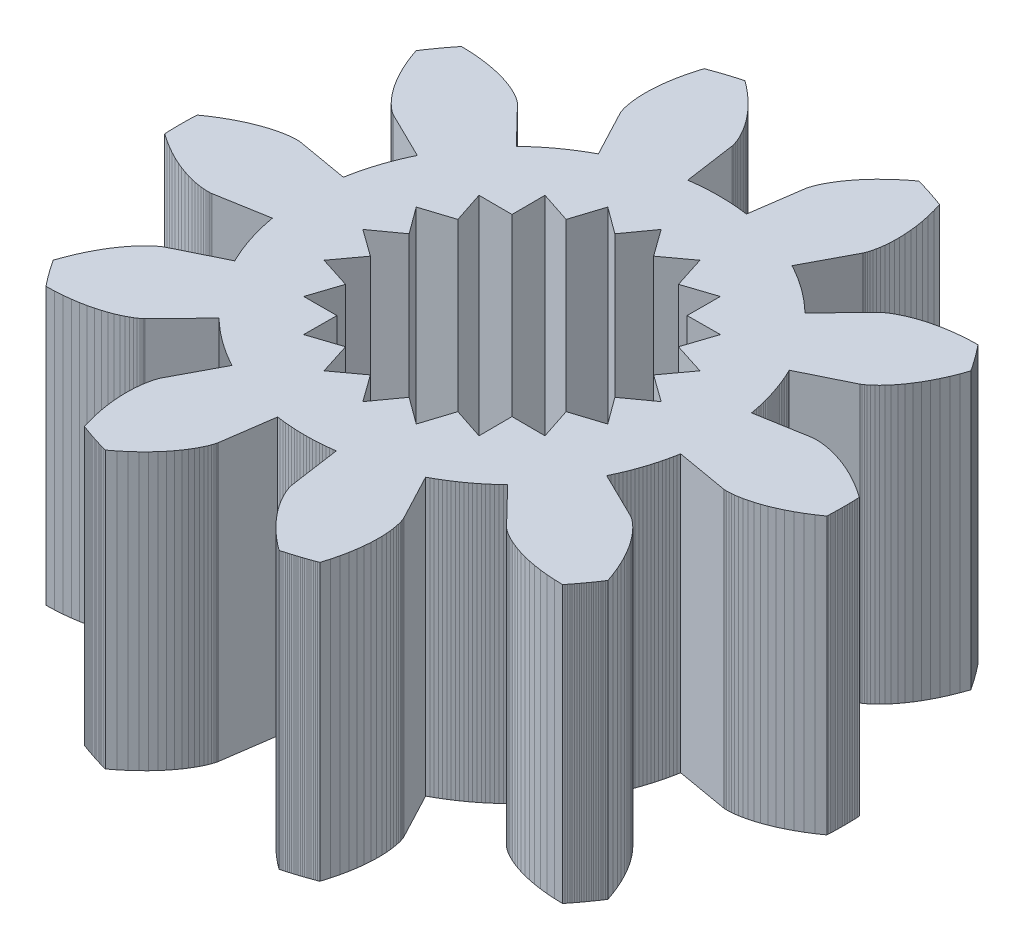
from build123d import *

# Parameters (mm, degrees)
BOSS_EXTRUDE1_DEPTH = 5
SKETCH2_R           = 1.5
CUT_EXTRUDE1_DEPTH  = 6
CUT_EXTRUDE2_DEPTH  = 6


with BuildPart() as part:
    # Sketch1 → Boss-Extrude1 (new body)
    with BuildSketch(Plane(origin=(0, 0, 0), x_dir=(1, 0, 0), z_dir=(0, 1, 0))):
        Polygon((3.6946769, -0.6417654), (4.6291475, -0.8040829), (4.6332094, -0.8046724), (4.6454524, -0.8059869), (4.6659298, -0.8073423), (4.6946521, -0.8080515), (4.7315867, -0.8074275), (4.7766581, -0.8047855), (4.8297479, -0.7994452), (4.8906949, -0.7907331), (4.9592959, -0.7779854), (5.035306, -0.7605497), (5.1184393, -0.7377878), (5.2083696, -0.7090775), (5.3047313, -0.6738155), (5.4071205, -0.631419), (5.515096, -0.5813282), (5.6281806, -0.523008), (5.7458624, -0.4559506), (5.8675963, -0.379677), (5.9928055, -0.2937389), (5.9942402, -0.26284), (5.9955155, -0.2319341), (5.9966316, -0.201022), (5.9975882, -0.1701046), (5.9983855, -0.1391826), (5.9990233, -0.108257), (5.9995017, -0.0773285), (5.9998206, -0.0463979), (5.9999801, -0.0154661), (5.9999801, 0.0154661), (5.9998206, 0.0463979), (5.9995017, 0.0773285), (5.9990233, 0.108257), (5.9983855, 0.1391826), (5.9975882, 0.1701046), (5.9966316, 0.201022), (5.9955155, 0.2319341), (5.9942402, 0.26284), (5.9928055, 0.2937389), (5.8675963, 0.379677), (5.7458624, 0.4559506), (5.6281806, 0.523008), (5.515096, 0.5813282), (5.4071205, 0.631419), (5.3047313, 0.6738155), (5.2083696, 0.7090775), (5.1184393, 0.7377878), (5.035306, 0.7605497), (4.9592959, 0.7779854), (4.8906949, 0.7907331), (4.8297479, 0.7994452), (4.7766581, 0.8047855), (4.7315867, 0.8074275), (4.6946521, 0.8080515), (4.6659298, 0.8073423), (4.6454524, 0.8059869), (4.6332094, 0.8046724), (4.6291475, 0.8040829), (3.6946769, 0.6417654), (3.6846589, 0.6969853), (3.6738157, 0.7520491), (3.6621497, 0.8069445), (3.6496635, 0.8616591), (3.6363598, 0.9161808), (3.6222417, 0.9704972), (3.6073123, 1.0245963), (3.591575, 1.078466), (3.5750333, 1.132094), (3.5576909, 1.1854685), (3.5395516, 1.2385775), (3.5206196, 1.2914091), (3.5008991, 1.3439515), (3.4803944, 1.3961929), (3.4591103, 1.4481215), (3.4370514, 1.4997258), (3.4142227, 1.5509942), (3.3906294, 1.6019152), (3.3662766, 1.6524775), (4.217687, 2.0704279), (4.2213197, 2.0723385), (4.2319972, 2.0784713), (4.2493604, 2.0894111), (4.2730141, 2.1057199), (4.3025281, 2.1279343), (4.3374387, 2.156564), (4.3772502, 2.1920898), (4.4214365, 2.2349618), (4.469443, 2.2855975), (4.520688, 2.3443809), (4.5745651, 2.4116603), (4.6304448, 2.4877471), (4.6876766, 2.5729146), (4.7455911, 2.6673969), (4.8035025, 2.7713877), (4.8607101, 2.8850392), (4.9165014, 3.0084614), (4.9701537, 3.1417214), (5.0209369, 3.2848429), (5.0039356, 3.3106839), (4.9868014, 3.336437), (4.9695346, 3.3621014), (4.9521358, 3.3876764), (4.9346053, 3.4131614), (4.9169437, 3.4385557), (4.8991514, 3.4638585), (4.8812288, 3.4890694), (4.8631766, 3.5141875), (4.8449951, 3.5392121), (4.8266848, 3.5641428), (4.8082463, 3.5889787), (4.7896799, 3.6137192), (4.7709863, 3.6383636), (4.7521658, 3.6629114), (4.7332191, 3.6873618), (4.7141465, 3.7117142), (4.6949487, 3.735968), (4.6756261, 3.7601225), (4.5238166, 3.7560517), (4.3804993, 3.746205), (4.2458773, 3.7312839), (4.1201102, 3.7119964), (4.0033136, 3.6890544), (3.8955589, 3.663171), (3.7968742, 3.6350586), (3.7072436, 3.605426), (3.6266082, 3.5749763), (3.5548663, 3.5444044), (3.491874, 3.5143949), (3.437446, 3.4856193), (3.3913565, 3.4587344), (3.3533401, 3.4343795), (3.3230926, 3.4131746), (3.3002726, 3.3957183), (3.2845027, 3.3825855), (3.2753706, 3.3743258), (3.2724309, 3.3714613), (2.6118362, 2.6908757), (2.571274, 2.7296611), (2.530136, 2.7678352), (2.4884313, 2.8053894), (2.4461693, 2.8423152), (2.4033593, 2.8786045), (2.3600111, 2.914249), (2.3161344, 2.9492408), (2.2717388, 2.9835721), (2.2268345, 3.0172352), (2.1814314, 3.0502224), (2.1355398, 3.0825265), (2.0891698, 3.1141402), (2.042332, 3.1450565), (1.9950367, 3.1752683), (1.9472946, 3.2047689), (1.8991163, 3.2335518), (1.8505127, 3.2616105), (1.8014946, 3.2889386), (1.7520731, 3.3155301), (2.1952135, 4.1541056), (2.1970294, 4.1577866), (2.2020629, 4.1690241), (2.2096797, 4.1880805), (2.2192299, 4.2151778), (2.2300499, 4.2504976), (2.2414651, 4.2941794), (2.2527917, 4.346321), (2.2633397, 4.4069772), (2.2724148, 4.4761599), (2.2793209, 4.5538378), (2.2833626, 4.6399361), (2.2838475, 4.7343368), (2.2800888, 4.8368788), (2.2714073, 4.9473579), (2.2571343, 5.0655277), (2.2366136, 5.1910994), (2.2092039, 5.3237434), (2.1742812, 5.463089), (2.1312411, 5.6087264), (2.1022978, 5.6196391), (2.0732986, 5.6304025), (2.0442444, 5.6410163), (2.0151358, 5.6514801), (1.9859736, 5.6617938), (1.9567587, 5.6719569), (1.9274917, 5.6819693), (1.8981736, 5.6918307), (1.868805, 5.7015408), (1.8393867, 5.7110994), (1.8099195, 5.7205062), (1.7804042, 5.729761), (1.7508416, 5.7388634), (1.7212325, 5.7478134), (1.6915776, 5.7566106), (1.6618778, 5.7652547), (1.6321338, 5.7737457), (1.6023464, 5.7820832), (1.5725164, 5.790267), (1.4520927, 5.6977423), (1.3419343, 5.6055363), (1.2417933, 5.5143362), (1.1513824, 5.4248082), (1.0703769, 5.3375964), (0.9984155, 5.2533197), (0.9351019, 5.1725708), (0.8800069, 5.095914), (0.8326693, 5.0238834), (0.7925986, 4.9569814), (0.7592759, 4.8956772), (0.7321566, 4.8404053), (0.710672, 4.7915643), (0.6942315, 4.7495152), (0.6822246, 4.7145811), (0.6740235, 4.6870454), (0.6689846, 4.6671514), (0.6664515, 4.6551015), (0.6657569, 4.6510561), (0.5313628, 3.7121629), (0.4757498, 3.7196992), (0.4200303, 3.7264024), (0.3642167, 3.7322709), (0.3083215, 3.7373036), (0.2523573, 3.7414991), (0.1963365, 3.7448567), (0.1402718, 3.7473756), (0.0841756, 3.7490551), (0.0280606, 3.749895), (-0.0280606, 3.749895), (-0.0841756, 3.7490551), (-0.1402718, 3.7473756), (-0.1963365, 3.7448567), (-0.2523573, 3.7414991), (-0.3083215, 3.7373036), (-0.3642167, 3.7322709), (-0.4200303, 3.7264024), (-0.4757498, 3.7196992), (-0.5313628, 3.7121629), (-0.6657569, 4.6510561), (-0.6664515, 4.6551015), (-0.6689846, 4.6671514), (-0.6740235, 4.6870454), (-0.6822246, 4.7145811), (-0.6942315, 4.7495152), (-0.710672, 4.7915643), (-0.7321566, 4.8404053), (-0.7592759, 4.8956772), (-0.7925986, 4.9569814), (-0.8326693, 5.0238834), (-0.8800069, 5.095914), (-0.9351019, 5.1725708), (-0.9984155, 5.2533197), (-1.0703769, 5.3375964), (-1.1513824, 5.4248082), (-1.2417933, 5.5143362), (-1.3419343, 5.6055363), (-1.4520927, 5.6977423), (-1.5725164, 5.790267), (-1.6023464, 5.7820832), (-1.6321338, 5.7737457), (-1.6618778, 5.7652547), (-1.6915776, 5.7566106), (-1.7212325, 5.7478134), (-1.7508416, 5.7388634), (-1.7804042, 5.729761), (-1.8099195, 5.7205062), (-1.8393867, 5.7110994), (-1.868805, 5.7015408), (-1.8981736, 5.6918307), (-1.9274917, 5.6819693), (-1.9567587, 5.6719569), (-1.9859736, 5.6617938), (-2.0151358, 5.6514801), (-2.0442444, 5.6410163), (-2.0732986, 5.6304025), (-2.1022978, 5.6196391), (-2.1312411, 5.6087264), (-2.1742812, 5.463089), (-2.2092039, 5.3237434), (-2.2366136, 5.1910994), (-2.2571343, 5.0655277), (-2.2714073, 4.9473579), (-2.2800888, 4.8368788), (-2.2838475, 4.7343368), (-2.2833626, 4.6399361), (-2.2793209, 4.5538378), (-2.2724148, 4.4761599), (-2.2633397, 4.4069772), (-2.2527917, 4.346321), (-2.2414651, 4.2941794), (-2.2300499, 4.2504976), (-2.2192299, 4.2151778), (-2.2096797, 4.1880805), (-2.2020629, 4.1690241), (-2.1970294, 4.1577866), (-2.1952135, 4.1541056), (-1.7520731, 3.3155301), (-1.8014946, 3.2889386), (-1.8505127, 3.2616105), (-1.8991163, 3.2335518), (-1.9472946, 3.2047689), (-1.9950367, 3.1752683), (-2.042332, 3.1450565), (-2.0891698, 3.1141402), (-2.1355398, 3.0825265), (-2.1814314, 3.0502224), (-2.2268345, 3.0172352), (-2.2717388, 2.9835721), (-2.3161344, 2.9492408), (-2.3600111, 2.914249), (-2.4033593, 2.8786045), (-2.4461693, 2.8423152), (-2.4884313, 2.8053894), (-2.530136, 2.7678352), (-2.571274, 2.7296611), (-2.6118362, 2.6908757), (-3.2724309, 3.3714613), (-3.2753706, 3.3743258), (-3.2845027, 3.3825855), (-3.3002726, 3.3957183), (-3.3230926, 3.4131746), (-3.3533401, 3.4343795), (-3.3913565, 3.4587344), (-3.437446, 3.4856193), (-3.491874, 3.5143949), (-3.5548663, 3.5444044), (-3.6266082, 3.5749763), (-3.7072436, 3.605426), (-3.7968742, 3.6350586), (-3.8955589, 3.663171), (-4.0033136, 3.6890544), (-4.1201102, 3.7119964), (-4.2458773, 3.7312839), (-4.3804993, 3.746205), (-4.5238166, 3.7560517), (-4.6756261, 3.7601225), (-4.6949487, 3.735968), (-4.7141465, 3.7117142), (-4.7332191, 3.6873618), (-4.7521658, 3.6629114), (-4.7709863, 3.6383636), (-4.7896799, 3.6137192), (-4.8082463, 3.5889787), (-4.8266848, 3.5641428), (-4.8449951, 3.5392121), (-4.8631766, 3.5141875), (-4.8812288, 3.4890694), (-4.8991514, 3.4638585), (-4.9169437, 3.4385557), (-4.9346053, 3.4131614), (-4.9521358, 3.3876764), (-4.9695346, 3.3621014), (-4.9868014, 3.336437), (-5.0039356, 3.3106839), (-5.0209369, 3.2848429), (-4.9701537, 3.1417214), (-4.9165014, 3.0084614), (-4.8607101, 2.8850392), (-4.8035025, 2.7713877), (-4.7455911, 2.6673969), (-4.6876766, 2.5729146), (-4.6304448, 2.4877471), (-4.5745651, 2.4116603), (-4.520688, 2.3443809), (-4.469443, 2.2855975), (-4.4214365, 2.2349618), (-4.3772502, 2.1920898), (-4.3374387, 2.156564), (-4.3025281, 2.1279343), (-4.2730141, 2.1057199), (-4.2493604, 2.0894111), (-4.2319972, 2.0784713), (-4.2213197, 2.0723385), (-4.217687, 2.0704279), (-3.3662766, 1.6524775), (-3.3906294, 1.6019152), (-3.4142227, 1.5509942), (-3.4370514, 1.4997258), (-3.4591103, 1.4481215), (-3.4803944, 1.3961929), (-3.5008991, 1.3439515), (-3.5206196, 1.2914091), (-3.5395516, 1.2385775), (-3.5576909, 1.1854685), (-3.5750333, 1.132094), (-3.591575, 1.078466), (-3.6073123, 1.0245963), (-3.6222417, 0.9704972), (-3.6363598, 0.9161808), (-3.6496635, 0.8616591), (-3.6621497, 0.8069445), (-3.6738157, 0.7520491), (-3.6846589, 0.6969853), (-3.6946769, 0.6417654), (-4.6291475, 0.8040829), (-4.6332094, 0.8046724), (-4.6454524, 0.8059869), (-4.6659298, 0.8073423), (-4.6946521, 0.8080515), (-4.7315867, 0.8074275), (-4.7766581, 0.8047855), (-4.8297479, 0.7994452), (-4.8906949, 0.7907331), (-4.9592959, 0.7779854), (-5.035306, 0.7605497), (-5.1184393, 0.7377878), (-5.2083696, 0.7090775), (-5.3047313, 0.6738155), (-5.4071205, 0.631419), (-5.515096, 0.5813282), (-5.6281806, 0.523008), (-5.7458624, 0.4559506), (-5.8675963, 0.379677), (-5.9928055, 0.2937389), (-5.9942402, 0.26284), (-5.9955155, 0.2319341), (-5.9966316, 0.201022), (-5.9975882, 0.1701046), (-5.9983855, 0.1391826), (-5.9990233, 0.108257), (-5.9995017, 0.0773285), (-5.9998206, 0.0463979), (-5.9999801, 0.0154661), (-5.9999801, -0.0154661), (-5.9998206, -0.0463979), (-5.9995017, -0.0773285), (-5.9990233, -0.108257), (-5.9983855, -0.1391826), (-5.9975882, -0.1701046), (-5.9966316, -0.201022), (-5.9955155, -0.2319341), (-5.9942402, -0.26284), (-5.9928055, -0.2937389), (-5.8675963, -0.379677), (-5.7458624, -0.4559506), (-5.6281806, -0.523008), (-5.515096, -0.5813282), (-5.4071205, -0.631419), (-5.3047313, -0.6738155), (-5.2083696, -0.7090775), (-5.1184393, -0.7377878), (-5.035306, -0.7605497), (-4.9592959, -0.7779854), (-4.8906949, -0.7907331), (-4.8297479, -0.7994452), (-4.7766581, -0.8047855), (-4.7315867, -0.8074275), (-4.6946521, -0.8080515), (-4.6659298, -0.8073423), (-4.6454524, -0.8059869), (-4.6332094, -0.8046724), (-4.6291475, -0.8040829), (-3.6946769, -0.6417654), (-3.6846589, -0.6969853), (-3.6738157, -0.7520491), (-3.6621497, -0.8069445), (-3.6496635, -0.8616591), (-3.6363598, -0.9161808), (-3.6222417, -0.9704972), (-3.6073123, -1.0245963), (-3.591575, -1.078466), (-3.5750333, -1.132094), (-3.5576909, -1.1854685), (-3.5395516, -1.2385775), (-3.5206196, -1.2914091), (-3.5008991, -1.3439515), (-3.4803944, -1.3961929), (-3.4591103, -1.4481215), (-3.4370514, -1.4997258), (-3.4142227, -1.5509942), (-3.3906294, -1.6019152), (-3.3662766, -1.6524775), (-4.217687, -2.0704279), (-4.2213197, -2.0723385), (-4.2319972, -2.0784713), (-4.2493604, -2.0894111), (-4.2730141, -2.1057199), (-4.3025281, -2.1279343), (-4.3374387, -2.156564), (-4.3772502, -2.1920898), (-4.4214365, -2.2349618), (-4.469443, -2.2855975), (-4.520688, -2.3443809), (-4.5745651, -2.4116603), (-4.6304448, -2.4877471), (-4.6876766, -2.5729146), (-4.7455911, -2.6673969), (-4.8035025, -2.7713877), (-4.8607101, -2.8850392), (-4.9165014, -3.0084614), (-4.9701537, -3.1417214), (-5.0209369, -3.2848429), (-5.0039356, -3.3106839), (-4.9868014, -3.336437), (-4.9695346, -3.3621014), (-4.9521358, -3.3876764), (-4.9346053, -3.4131614), (-4.9169437, -3.4385557), (-4.8991514, -3.4638585), (-4.8812288, -3.4890694), (-4.8631766, -3.5141875), (-4.8449951, -3.5392121), (-4.8266848, -3.5641428), (-4.8082463, -3.5889787), (-4.7896799, -3.6137192), (-4.7709863, -3.6383636), (-4.7521658, -3.6629114), (-4.7332191, -3.6873618), (-4.7141465, -3.7117142), (-4.6949487, -3.735968), (-4.6756261, -3.7601225), (-4.5238166, -3.7560517), (-4.3804993, -3.746205), (-4.2458773, -3.7312839), (-4.1201102, -3.7119964), (-4.0033136, -3.6890544), (-3.8955589, -3.663171), (-3.7968742, -3.6350586), (-3.7072436, -3.605426), (-3.6266082, -3.5749763), (-3.5548663, -3.5444044), (-3.491874, -3.5143949), (-3.437446, -3.4856193), (-3.3913565, -3.4587344), (-3.3533401, -3.4343795), (-3.3230926, -3.4131746), (-3.3002726, -3.3957183), (-3.2845027, -3.3825855), (-3.2753706, -3.3743258), (-3.2724309, -3.3714613), (-2.6118362, -2.6908757), (-2.571274, -2.7296611), (-2.530136, -2.7678352), (-2.4884313, -2.8053894), (-2.4461693, -2.8423152), (-2.4033593, -2.8786045), (-2.3600111, -2.914249), (-2.3161344, -2.9492408), (-2.2717388, -2.9835721), (-2.2268345, -3.0172352), (-2.1814314, -3.0502224), (-2.1355398, -3.0825265), (-2.0891698, -3.1141402), (-2.042332, -3.1450565), (-1.9950367, -3.1752683), (-1.9472946, -3.2047689), (-1.8991163, -3.2335518), (-1.8505127, -3.2616105), (-1.8014946, -3.2889386), (-1.7520731, -3.3155301), (-2.1952135, -4.1541056), (-2.1970294, -4.1577866), (-2.2020629, -4.1690241), (-2.2096797, -4.1880805), (-2.2192299, -4.2151778), (-2.2300499, -4.2504976), (-2.2414651, -4.2941794), (-2.2527917, -4.346321), (-2.2633397, -4.4069772), (-2.2724148, -4.4761599), (-2.2793209, -4.5538378), (-2.2833626, -4.6399361), (-2.2838475, -4.7343368), (-2.2800888, -4.8368788), (-2.2714073, -4.9473579), (-2.2571343, -5.0655277), (-2.2366136, -5.1910994), (-2.2092039, -5.3237434), (-2.1742812, -5.463089), (-2.1312411, -5.6087264), (-2.1022978, -5.6196391), (-2.0732986, -5.6304025), (-2.0442444, -5.6410163), (-2.0151358, -5.6514801), (-1.9859736, -5.6617938), (-1.9567587, -5.6719569), (-1.9274917, -5.6819693), (-1.8981736, -5.6918307), (-1.868805, -5.7015408), (-1.8393867, -5.7110994), (-1.8099195, -5.7205062), (-1.7804042, -5.729761), (-1.7508416, -5.7388634), (-1.7212325, -5.7478134), (-1.6915776, -5.7566106), (-1.6618778, -5.7652547), (-1.6321338, -5.7737457), (-1.6023464, -5.7820832), (-1.5725164, -5.790267), (-1.4520927, -5.6977423), (-1.3419343, -5.6055363), (-1.2417933, -5.5143362), (-1.1513824, -5.4248082), (-1.0703769, -5.3375964), (-0.9984155, -5.2533197), (-0.9351019, -5.1725708), (-0.8800069, -5.095914), (-0.8326693, -5.0238834), (-0.7925986, -4.9569814), (-0.7592759, -4.8956772), (-0.7321566, -4.8404053), (-0.710672, -4.7915643), (-0.6942315, -4.7495152), (-0.6822246, -4.7145811), (-0.6740235, -4.6870454), (-0.6689846, -4.6671514), (-0.6664515, -4.6551015), (-0.6657569, -4.6510561), (-0.5313628, -3.7121629), (-0.4757498, -3.7196992), (-0.4200303, -3.7264024), (-0.3642167, -3.7322709), (-0.3083215, -3.7373036), (-0.2523573, -3.7414991), (-0.1963365, -3.7448567), (-0.1402718, -3.7473756), (-0.0841756, -3.7490551), (-0.0280606, -3.749895), (0.0280606, -3.749895), (0.0841756, -3.7490551), (0.1402718, -3.7473756), (0.1963365, -3.7448567), (0.2523573, -3.7414991), (0.3083215, -3.7373036), (0.3642167, -3.7322709), (0.4200303, -3.7264024), (0.4757498, -3.7196992), (0.5313628, -3.7121629), (0.6657569, -4.6510561), (0.6664515, -4.6551015), (0.6689846, -4.6671514), (0.6740235, -4.6870454), (0.6822246, -4.7145811), (0.6942315, -4.7495152), (0.710672, -4.7915643), (0.7321566, -4.8404053), (0.7592759, -4.8956772), (0.7925986, -4.9569814), (0.8326693, -5.0238834), (0.8800069, -5.095914), (0.9351019, -5.1725708), (0.9984155, -5.2533197), (1.0703769, -5.3375964), (1.1513824, -5.4248082), (1.2417933, -5.5143362), (1.3419343, -5.6055363), (1.4520927, -5.6977423), (1.5725164, -5.790267), (1.6023464, -5.7820832), (1.6321338, -5.7737457), (1.6618778, -5.7652547), (1.6915776, -5.7566106), (1.7212325, -5.7478134), (1.7508416, -5.7388634), (1.7804042, -5.729761), (1.8099195, -5.7205062), (1.8393867, -5.7110994), (1.868805, -5.7015408), (1.8981736, -5.6918307), (1.9274917, -5.6819693), (1.9567587, -5.6719569), (1.9859736, -5.6617938), (2.0151358, -5.6514801), (2.0442444, -5.6410163), (2.0732986, -5.6304025), (2.1022978, -5.6196391), (2.1312411, -5.6087264), (2.1742812, -5.463089), (2.2092039, -5.3237434), (2.2366136, -5.1910994), (2.2571343, -5.0655277), (2.2714073, -4.9473579), (2.2800888, -4.8368788), (2.2838475, -4.7343368), (2.2833626, -4.6399361), (2.2793209, -4.5538378), (2.2724148, -4.4761599), (2.2633397, -4.4069772), (2.2527917, -4.346321), (2.2414651, -4.2941794), (2.2300499, -4.2504976), (2.2192299, -4.2151778), (2.2096797, -4.1880805), (2.2020629, -4.1690241), (2.1970294, -4.1577866), (2.1952135, -4.1541056), (1.7520731, -3.3155301), (1.8014946, -3.2889386), (1.8505127, -3.2616105), (1.8991163, -3.2335518), (1.9472946, -3.2047689), (1.9950367, -3.1752683), (2.042332, -3.1450565), (2.0891698, -3.1141402), (2.1355398, -3.0825265), (2.1814314, -3.0502224), (2.2268345, -3.0172352), (2.2717388, -2.9835721), (2.3161344, -2.9492408), (2.3600111, -2.914249), (2.4033593, -2.8786045), (2.4461693, -2.8423152), (2.4884313, -2.8053894), (2.530136, -2.7678352), (2.571274, -2.7296611), (2.6118362, -2.6908757), (3.2724309, -3.3714613), (3.2753706, -3.3743258), (3.2845027, -3.3825855), (3.3002726, -3.3957183), (3.3230926, -3.4131746), (3.3533401, -3.4343795), (3.3913565, -3.4587344), (3.437446, -3.4856193), (3.491874, -3.5143949), (3.5548663, -3.5444044), (3.6266082, -3.5749763), (3.7072436, -3.605426), (3.7968742, -3.6350586), (3.8955589, -3.663171), (4.0033136, -3.6890544), (4.1201102, -3.7119964), (4.2458773, -3.7312839), (4.3804993, -3.746205), (4.5238166, -3.7560517), (4.6756261, -3.7601225), (4.6949487, -3.735968), (4.7141465, -3.7117142), (4.7332191, -3.6873618), (4.7521658, -3.6629114), (4.7709863, -3.6383636), (4.7896799, -3.6137192), (4.8082463, -3.5889787), (4.8266848, -3.5641428), (4.8449951, -3.5392121), (4.8631766, -3.5141875), (4.8812288, -3.4890694), (4.8991514, -3.4638585), (4.9169437, -3.4385557), (4.9346053, -3.4131614), (4.9521358, -3.3876764), (4.9695346, -3.3621014), (4.9868014, -3.336437), (5.0039356, -3.3106839), (5.0209369, -3.2848429), (4.9701537, -3.1417214), (4.9165014, -3.0084614), (4.8607101, -2.8850392), (4.8035025, -2.7713877), (4.7455911, -2.6673969), (4.6876766, -2.5729146), (4.6304448, -2.4877471), (4.5745651, -2.4116603), (4.520688, -2.3443809), (4.469443, -2.2855975), (4.4214365, -2.2349618), (4.3772502, -2.1920898), (4.3374387, -2.156564), (4.3025281, -2.1279343), (4.2730141, -2.1057199), (4.2493604, -2.0894111), (4.2319972, -2.0784713), (4.2213197, -2.0723385), (4.217687, -2.0704279), (3.3662766, -1.6524775), (3.3906294, -1.6019152), (3.4142227, -1.5509942), (3.4370514, -1.4997258), (3.4591103, -1.4481215), (3.4803944, -1.3961929), (3.5008991, -1.3439515), (3.5206196, -1.2914091), (3.5395516, -1.2385775), (3.5576909, -1.1854685), (3.5750333, -1.132094), (3.591575, -1.078466), (3.6073123, -1.0245963), (3.6222417, -0.9704972), (3.6363598, -0.9161808), (3.6496635, -0.8616591), (3.6621497, -0.8069445), (3.6738157, -0.7520491), (3.6846589, -0.6969853), align=None)
    extrude(amount=BOSS_EXTRUDE1_DEPTH)

    # Sketch2 → Cut-Extrude1 (cut, through all)
    with BuildSketch(Plane(origin=(0, 5, 0), x_dir=(1, 0, 0), z_dir=(0, 1, 0))):
        Circle(SKETCH2_R)
    extrude(amount=-CUT_EXTRUDE1_DEPTH, mode=Mode.SUBTRACT)

    # Sketch4 → Cut-Extrude2 (cut, through all)
    with BuildSketch(Plane(origin=(0, 5, 0), x_dir=(1, 0, 0), z_dir=(0, 1, 0))):
        Polygon((-0.350508913, 2.213026179), (0, 2.7), (0.350508913, 2.213026179), (0.834345885, 2.567852594), (1.017216484, 1.996399758), (1.587020181, 2.184345885), (1.584351818, 1.584351818), (2.184345885, 1.587020181), (1.996399758, 1.017216484), (2.567852594, 0.834345885), (2.213026179, 0.350508913), (2.7, 0), (2.213026179, -0.350508913), (2.567852594, -0.834345885), (1.996399758, -1.017216484), (2.184345885, -1.587020181), (1.584351818, -1.584351818), (1.587020181, -2.184345885), (1.017216484, -1.996399758), (0.834345885, -2.567852594), (0.350508913, -2.213026179), (0, -2.7), (-0.350508913, -2.213026179), (-0.834345885, -2.567852594), (-1.017216484, -1.996399758), (-1.587020181, -2.184345885), (-1.584351818, -1.584351818), (-2.184345885, -1.587020181), (-1.996399758, -1.017216484), (-2.567852594, -0.834345885), (-2.213026179, -0.350508913), (-2.7, 0), (-2.213026179, 0.350508913), (-2.567852594, 0.834345885), (-1.996399758, 1.017216484), (-2.184345885, 1.587020181), (-1.584351818, 1.584351818), (-1.587020181, 2.184345885), (-1.017216484, 1.996399758), (-0.834345885, 2.567852594), align=None)
    extrude(amount=-CUT_EXTRUDE2_DEPTH, mode=Mode.SUBTRACT)


solid = part.part
